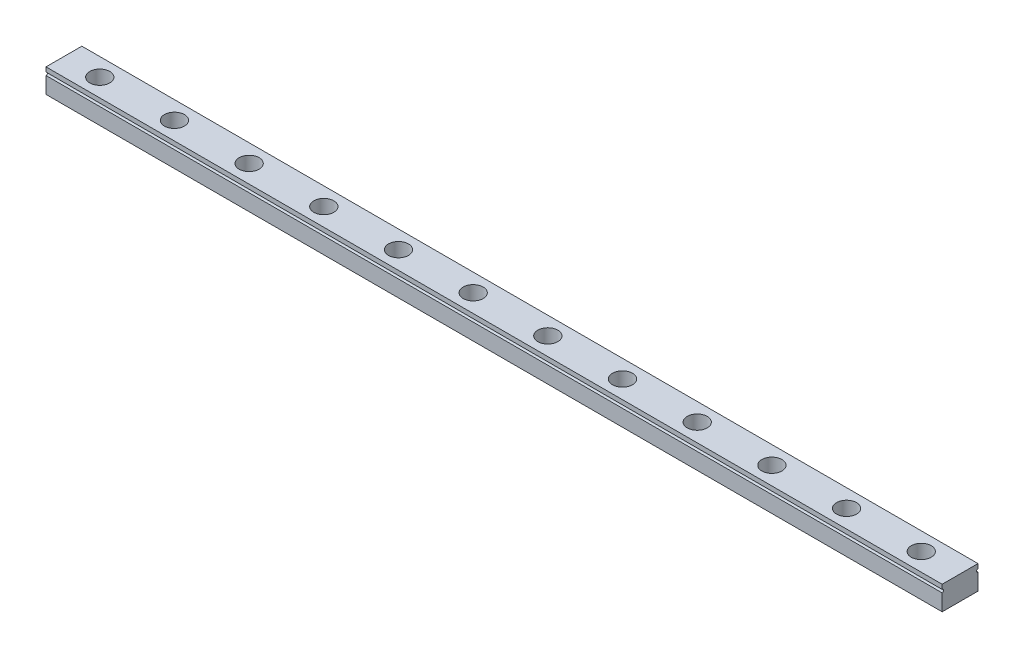
from build123d import *

# Parameters (mm, degrees)
BOSS_EXTRUDE1_DEPTH                         = 300
CBORE_FOR_M3_BUTTON_HEAD_SCREW1_D           = 3.4
CBORE_FOR_M3_BUTTON_HEAD_SCREW1_CBORE_D     = 6.7
CBORE_FOR_M3_BUTTON_HEAD_SCREW1_CBORE_DEPTH = 6.15
LPATTERN1_COUNT                             = 12
LPATTERN1_PITCH                             = 25


with BuildPart() as part:
    # Sketch1 → Boss-Extrude1 (new body)
    with BuildSketch(Plane(origin=(0, 0, 0), x_dir=(0, 0, -1), z_dir=(1, 0, 0))):
        with BuildLine():
            Line((0, 5.5), (0, 0))
            Line((0, 0), (12, 0))
            Line((12, 0), (12, 5.5))
            ThreePointArc((12, 5.5), (11.5, 6), (12, 6.5))
            Line((12, 6.5), (12, 8))
            Line((12, 8), (0, 8))
            Line((0, 8), (0, 6.5))
            ThreePointArc((0, 6.5), (0.5, 6), (0, 5.5))
        make_face()
    extrude(amount=-BOSS_EXTRUDE1_DEPTH)

    # CBORE for M3 Button Head Screw1 (through all)
    with Locations(Plane(origin=(0, 8, 0), x_dir=(1, 0, 0), z_dir=(0, 1, 0))):
        with Locations((-288, 6)):
            cbore_for_m3_button_head_screw1 = CounterBoreHole(CBORE_FOR_M3_BUTTON_HEAD_SCREW1_D / 2, CBORE_FOR_M3_BUTTON_HEAD_SCREW1_CBORE_D / 2, CBORE_FOR_M3_BUTTON_HEAD_SCREW1_CBORE_DEPTH)

    # LPattern1: CBORE for M3 Button Head Screw1 ×12
    with Locations(*[(i * LPATTERN1_PITCH, 0, 0) for i in range(1, LPATTERN1_COUNT)]):
        add(cbore_for_m3_button_head_screw1, mode=Mode.SUBTRACT)


solid = part.part
